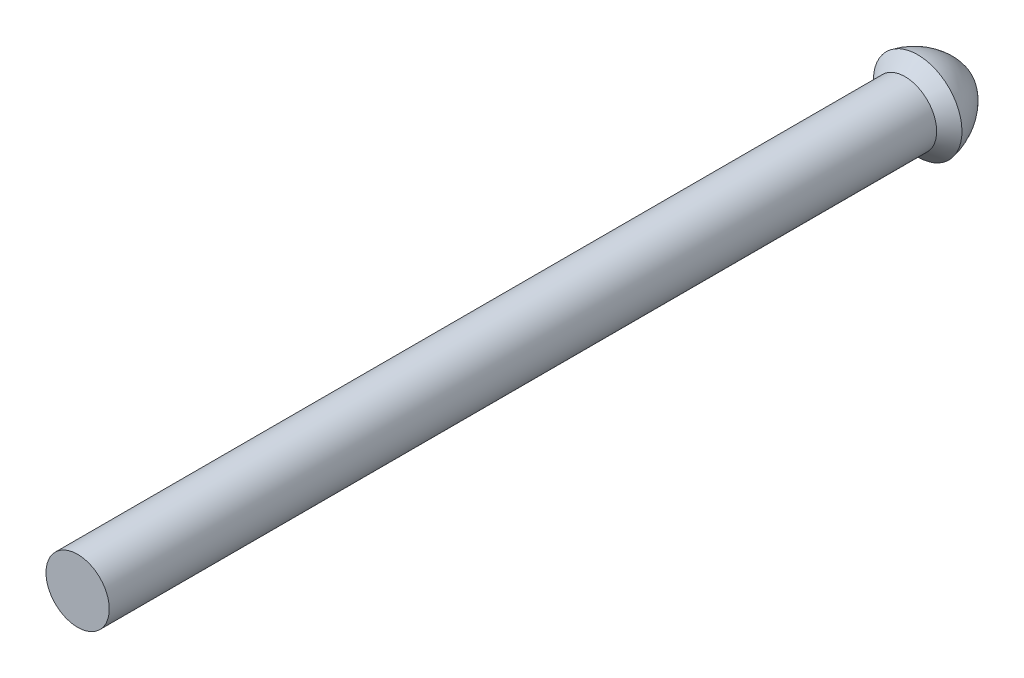
from build123d import *


with BuildPart() as part:
    # Sketch1 → Revolve2 (revolve)
    with BuildSketch(Plane(origin=(0, 0, 0), x_dir=(0, 0, -1), z_dir=(1, 0, 0))):
        with BuildLine():
            Line((99.629853384, 3.81), (101.153853384, 5.334))
            ThreePointArc((101.153853384, 5.334), (104.917385939, 3.490294477), (107.237142783, 0))
            Line((107.237142783, 0), (0, 0))
            Line((0, 0), (0, 3.81))
            Line((0, 3.81), (99.629853384, 3.81))
        make_face()
    revolve(axis=Axis((0, 0, 0), (0, 0, -1)))


solid = part.part
